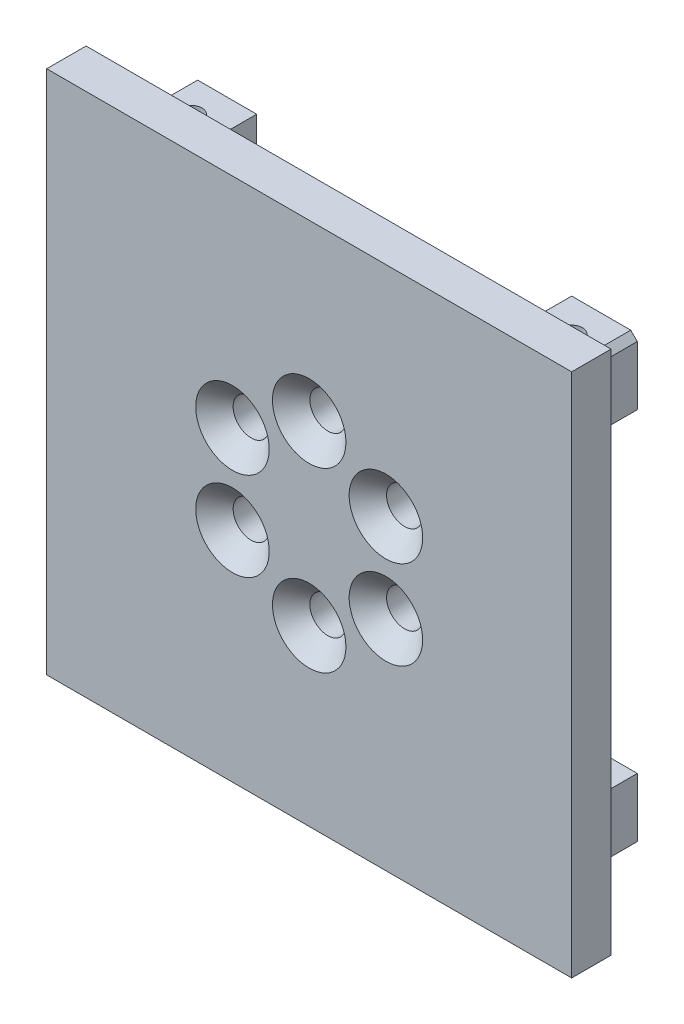
from build123d import *

# Parameters (mm, degrees)
SKETCH_1_W                   = 80
SKETCH_1_H                   = 80
EXTRUDE_1_DEPTH              = 6
SKETCH_11_W                  = 10
SKETCH_11_H                  = 10
EXTRUDE_3_DEPTH              = 10
HOLE_WIZARD_M4_2_D           = 3.3
HOLE_WIZARD_M4_2_DEPTH       = 68
HOLE_WIZARD_M5_1_D           = 5.5
HOLE_WIZARD_M5_1_DEPTH       = 6
HOLE_WIZARD_M5_1_CSINK_D     = 11.2
HOLE_WIZARD_M5_1_CSINK_ANGLE = 90
MIRROR_2_COPY_1_SKETCH_W     = 10
MIRROR_2_COPY_1_SKETCH_H     = 10
MIRROR_2_COPY_1_DEPTH        = 10
MIRROR_2_COPY_2_D            = 3.3
MIRROR_2_COPY_2_DEPTH        = 68
CHAMFER_1_SIZE               = 1


with BuildPart() as part:
    # 스케치1 → 보스-돌출1 (new body)
    with BuildSketch(Plane.XY):
        Rectangle(SKETCH_1_W, SKETCH_1_H)
    extrude(amount=EXTRUDE_1_DEPTH)

    # 스케치11 → 보스-돌출3 (add)
    with BuildSketch(Plane(origin=(0, 0, 0), x_dir=(-1, 0, 0), z_dir=(0, 0, -1))):
        with Locations((29, 29)):
            Rectangle(SKETCH_11_W, SKETCH_11_H)
    extrude_3 = extrude(amount=EXTRUDE_3_DEPTH)

    # M4 나사 구멍2
    with Locations(Plane(origin=(0, 34, 0), x_dir=(1, 0, 0), z_dir=(0, 1, 0))):
        with Locations((-29, 5)):
            hole_wizard_m4_2 = Hole(HOLE_WIZARD_M4_2_D / 2, depth=HOLE_WIZARD_M4_2_DEPTH)

    # M5 육각 소켓 접시 머리 캡 나사용 카운터싱크1
    with Locations(Plane.XY.offset(6)):
        with Locations((-11.691342951, -6.75), (0, -13.5), (11.691342951, -6.75), (11.691342951, 6.75), (0, 13.5), (-11.691342951, 6.75)):
            CounterSinkHole(HOLE_WIZARD_M5_1_D / 2, HOLE_WIZARD_M5_1_CSINK_D / 2, depth=HOLE_WIZARD_M5_1_DEPTH, counter_sink_angle=HOLE_WIZARD_M5_1_CSINK_ANGLE)

    # 대칭 복사1: 보스-돌출3, M4 나사 구멍2 across plane
    add(extrude_3.mirror(Plane(origin=(0, 0, 0), x_dir=(0, 0, 1), z_dir=(1, 0, 0))))
    add(hole_wizard_m4_2.mirror(Plane(origin=(0, 0, 0), x_dir=(0, 0, 1), z_dir=(1, 0, 0))), mode=Mode.SUBTRACT)

    # 대칭 복사2: 보스-돌출3, M4 나사 구멍2 across plane
    add(extrude_3.mirror(Plane.ZX))
    add(hole_wizard_m4_2.mirror(Plane.ZX), mode=Mode.SUBTRACT)

    # 대칭 복사2 copy 1 sketch → 대칭 복사2 copy 1 (add)
    with BuildSketch(Plane(origin=(0, 0, 0), x_dir=(1, 0, 0), z_dir=(0, 0, -1))):
        with Locations((29, 29)):
            Rectangle(MIRROR_2_COPY_1_SKETCH_W, MIRROR_2_COPY_1_SKETCH_H)
    extrude(amount=MIRROR_2_COPY_1_DEPTH)

    # 대칭 복사2 copy 2
    with Locations(Plane(origin=(0, -34, 0), x_dir=(-1, 0, 0), z_dir=(0, -1, 0))):
        with Locations((-29, 5)):
            Hole(MIRROR_2_COPY_2_D / 2, depth=MIRROR_2_COPY_2_DEPTH)

    # 모따기1
    chamfer_1_edges = [part.edges().sort_by_distance(p)[0] for p in [
        (34, -34, -5),
        (-34, -34, -5),
        (-34, 34, -5),
        (34, 34, -5),
    ]]
    chamfer(chamfer_1_edges, length=CHAMFER_1_SIZE)


solid = part.part
